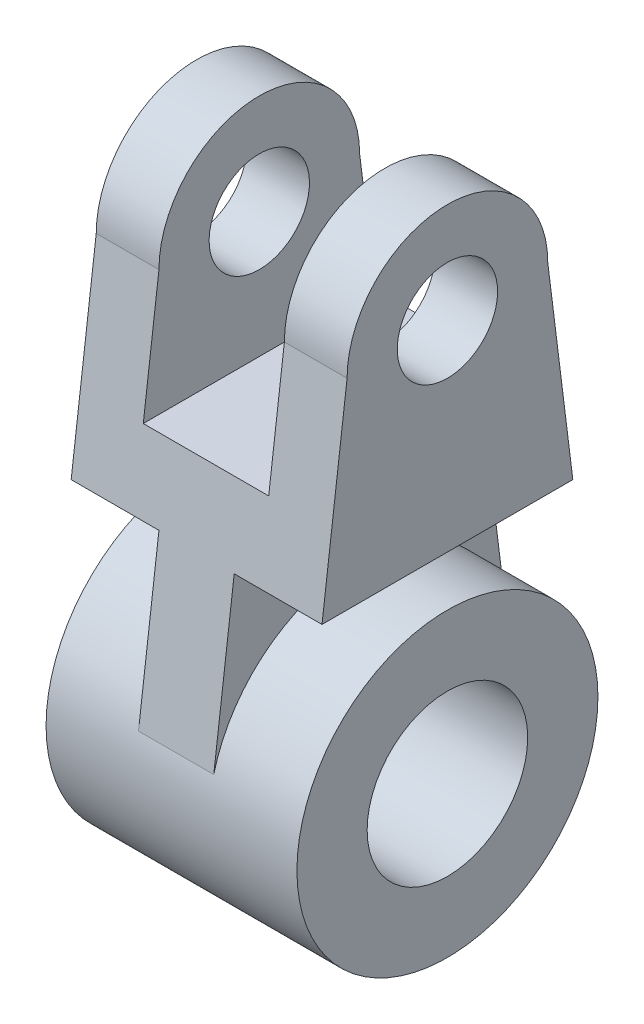
from build123d import *

# Parameters (mm, degrees)
SKETCH1_R           = 30
SKETCH1_R_2         = 16
BOSS_EXTRUDE1_DEPTH = 25
SKETCH4_R           = 10
BOSS_EXTRUDE3_DEPTH = 25
SKETCH7_W           = 15
SKETCH7_H           = 50
SKETCH8_W           = 15
SKETCH8_H           = 60
SKETCH9_R           = 16
CUT_EXTRUDE1_DEPTH  = 50
SKETCH11_W          = 25
SKETCH11_H          = 50
CUT_EXTRUDE3_DEPTH  = 54.5


with BuildPart() as part:
    # Sketch1 → Boss-Extrude1 (new body, symmetric)
    with BuildSketch(Plane(origin=(0, 0, 0), x_dir=(0, 0, -1), z_dir=(1, 0, 0))):
        Circle(SKETCH1_R)
        Circle(SKETCH1_R_2, mode=Mode.SUBTRACT)
    extrude(amount=BOSS_EXTRUDE1_DEPTH, both=True)



with BuildPart() as body_2:
    # Sketch4 → Boss-Extrude3 (new body, symmetric)
    with BuildSketch(Plane(origin=(0, 0, 0), x_dir=(0, 0, -1), z_dir=(1, 0, 0))):
        with BuildLine():
            Line((-20, 80), (-25, 40))
            Line((-25, 40), (25, 40))
            Line((25, 40), (20, 80))
            ThreePointArc((20, 80), (0, 100), (-20, 80))
        make_face()
        with Locations((0, 80)):
            Circle(SKETCH4_R, mode=Mode.SUBTRACT)
    extrude(amount=BOSS_EXTRUDE3_DEPTH, both=True)


with BuildPart() as part_1:
    add(part.part)

    add(body_2.part)  # Loft1 merges body 2
    # Sketch7 → Loft1 section 0
    with BuildSketch(Plane.XZ.offset(-40)):
        Rectangle(SKETCH7_W, SKETCH7_H)
    # Sketch8 → Loft1 section 1
    with BuildSketch(Plane(origin=(0, 0, 0), x_dir=(1, 0, 0), z_dir=(0, 1, 0))):
        Rectangle(SKETCH8_W, SKETCH8_H)
    loft()

    # Sketch9 → Cut-Extrude1 (cut)
    with BuildSketch(Plane(origin=(25, 0, 0), x_dir=(0, 0, -1), z_dir=(1, 0, 0))):
        Circle(SKETCH9_R)
    extrude(amount=-CUT_EXTRUDE1_DEPTH, mode=Mode.SUBTRACT)

    # Sketch11 → Cut-Extrude3 (cut, symmetric)
    with BuildSketch(Plane.XY):
        with Locations((0, 80)):
            Rectangle(SKETCH11_W, SKETCH11_H)
    extrude(amount=CUT_EXTRUDE3_DEPTH, both=True, mode=Mode.SUBTRACT)


solid = part_1.part
